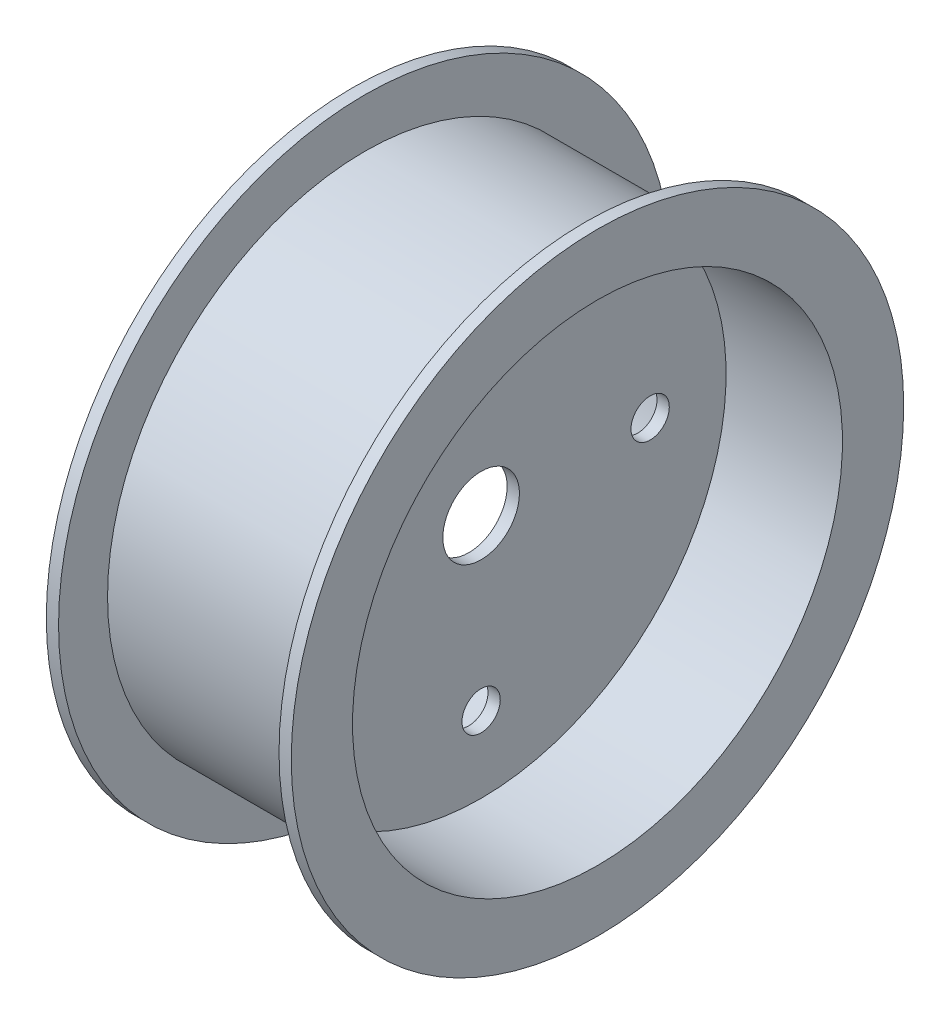
from build123d import *

# Parameters (mm, degrees)
CUT_EXTRUDE1_REACH = 28.67
SKETCH2_R          = 3.96875
SKETCH2_R_2        = 7.9375


with BuildPart() as part:
    # Sketch1 → Revolve1 (revolve)
    with BuildSketch(Plane.XY):
        Polygon((0, 0), (-1.27, 0), (-1.27, 50.8), (-25.4, 50.8), (-25.4, 63.5), (-22.86, 63.5), (-22.86, 53.34), (0, 53.34), (0, 50.8), align=None)
    revolve1 = revolve(axis=Axis((0, 0, 0), (-1, 0, 0)))

    # Mirror1: Revolve1 across plane
    add(revolve1.mirror(Plane(origin=(0, 0, 0), x_dir=(0, 0, 1), z_dir=(1, 0, 0))))

    # Sketch2 → Cut-Extrude1 (cut, up to next)
    with BuildSketch(Plane(origin=(1.27, 0, 0), x_dir=(0, 0, -1), z_dir=(1, 0, 0)), mode=Mode.PRIVATE) as cut_extrude1_sk1:
        with Locations((35.052, 0)):
            Circle(SKETCH2_R)
    cut_extrude1_tool1 = extrude(cut_extrude1_sk1.sketch, amount=-CUT_EXTRUDE1_REACH, mode=Mode.PRIVATE) & part.part
    add(cut_extrude1_tool1.solids().sort_by_distance((1.27, 0, -35.052))[0], mode=Mode.SUBTRACT)
    # Sketch2 → Cut-Extrude1 (cut, up to next)
    with BuildSketch(Plane(origin=(1.27, 0, 0), x_dir=(0, 0, -1), z_dir=(1, 0, 0)), mode=Mode.PRIVATE) as cut_extrude1_sk2:
        with Locations((0, 35.052)):
            Circle(SKETCH2_R)
    cut_extrude1_tool2 = extrude(cut_extrude1_sk2.sketch, amount=-CUT_EXTRUDE1_REACH, mode=Mode.PRIVATE) & part.part
    add(cut_extrude1_tool2.solids().sort_by_distance((1.27, 35.052, 0))[0], mode=Mode.SUBTRACT)
    # Sketch2 → Cut-Extrude1 (cut, up to next)
    with BuildSketch(Plane(origin=(1.27, 0, 0), x_dir=(0, 0, -1), z_dir=(1, 0, 0)), mode=Mode.PRIVATE) as cut_extrude1_sk3:
        with Locations((0, -35.052)):
            Circle(SKETCH2_R)
    cut_extrude1_tool3 = extrude(cut_extrude1_sk3.sketch, amount=-CUT_EXTRUDE1_REACH, mode=Mode.PRIVATE) & part.part
    add(cut_extrude1_tool3.solids().sort_by_distance((1.27, -35.052, 0))[0], mode=Mode.SUBTRACT)
    # Sketch2 → Cut-Extrude1 (cut, up to next)
    with BuildSketch(Plane(origin=(1.27, 0, 0), x_dir=(0, 0, -1), z_dir=(1, 0, 0)), mode=Mode.PRIVATE) as cut_extrude1_sk4:
        with Locations((-35.052, 0)):
            Circle(SKETCH2_R)
    cut_extrude1_tool4 = extrude(cut_extrude1_sk4.sketch, amount=-CUT_EXTRUDE1_REACH, mode=Mode.PRIVATE) & part.part
    add(cut_extrude1_tool4.solids().sort_by_distance((1.27, 0, 35.052))[0], mode=Mode.SUBTRACT)
    # Sketch2 → Cut-Extrude1 (cut, up to next)
    with BuildSketch(Plane(origin=(1.27, 0, 0), x_dir=(0, 0, -1), z_dir=(1, 0, 0)), mode=Mode.PRIVATE) as cut_extrude1_sk5:
        Circle(SKETCH2_R_2)
    cut_extrude1_tool5 = extrude(cut_extrude1_sk5.sketch, amount=-CUT_EXTRUDE1_REACH, mode=Mode.PRIVATE) & part.part
    add(cut_extrude1_tool5.solids().sort_by_distance((1.27, 0, 0))[0], mode=Mode.SUBTRACT)


solid = part.part
